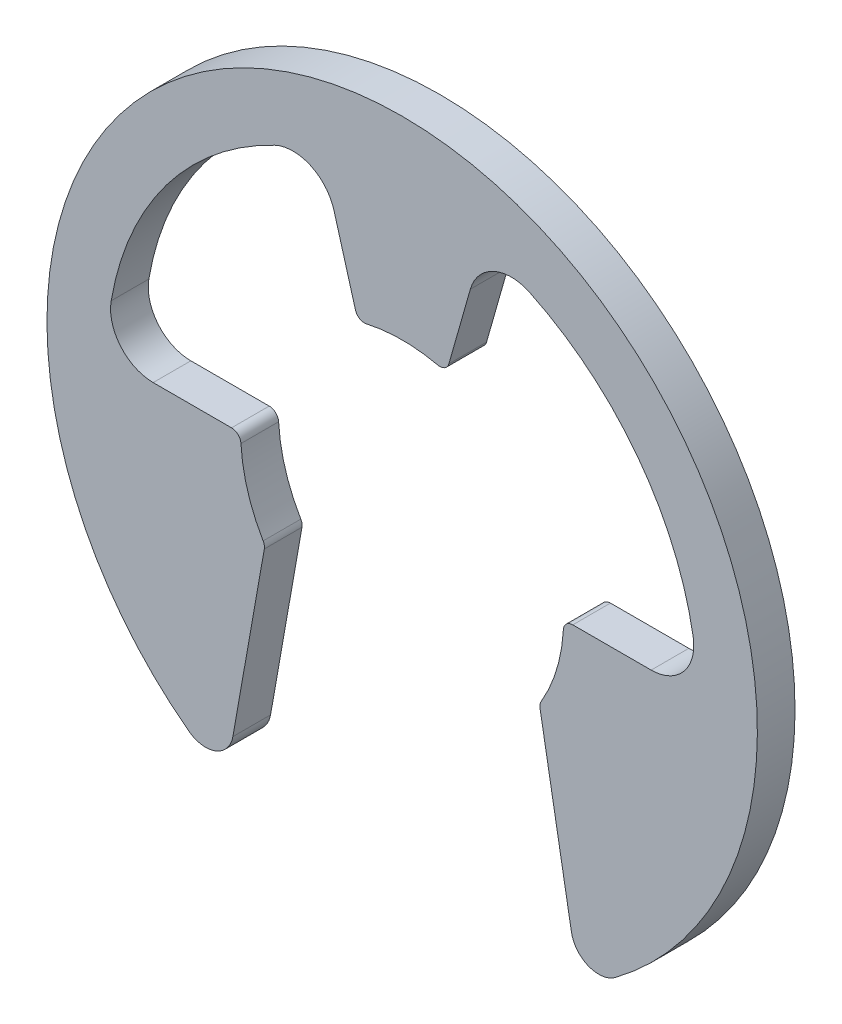
from build123d import *

# Parameters (mm, degrees)
SKETCH3_W               = 8.382
SKETCH3_H               = 0.889
CUT_EXTRUDE1_DEPTH      = 1.4445
CUT_EXTRUDE1_DEPTH_BACK = 1.4445
FILLET1_R               = 1.00584
FILLET2_R               = 0.653796
FILLET3_R               = 0.22225


with BuildPart() as part:
    # Sketch3 → Revolve1 (revolve)
    with BuildSketch(Plane(origin=(0, 0, 0), x_dir=(1, 0, 0), z_dir=(0, 1, 0))):
        with Locations((-4.191, 0)):
            Rectangle(SKETCH3_W, SKETCH3_H)
    revolve(axis=Axis((0, 0, -0.4445), (0, 0, 1)))

    # Sketch4 → Cut-Extrude1 (cut, two sides)
    with BuildSketch(Plane.XY) as cut_extrude1_sk:
        with BuildLine():
            Line((1.043411472, 3.664340664), (1.907952406, 6.700508642))
            ThreePointArc((1.907952406, 6.700508642), (5.560104779, 4.197896295), (6.966857143, 0))
            Line((6.966857143, 0), (3.81, 0))
            ThreePointArc((3.81, 0), (3.664340664, -1.043411472), (3.2385, -2.00704204))
            Line((3.2385, -2.00704204), (4.167000213, -7.27282842))
            ThreePointArc((4.167000213, -7.27282842), (0, -8.382), (-4.167000213, -7.27282842))
            Line((-4.167000213, -7.27282842), (-3.2385, -2.00704204))
            ThreePointArc((-3.2385, -2.00704204), (-3.664340664, -1.043411472), (-3.81, 0))
            Line((-3.81, 0), (-6.966857143, 0))
            ThreePointArc((-6.966857143, 0), (-5.560104779, 4.197896295), (-1.907952406, 6.700508642))
            Line((-1.907952406, 6.700508642), (-1.043411472, 3.664340664))
            ThreePointArc((-1.043411472, 3.664340664), (0, 3.81), (1.043411472, 3.664340664))
        make_face()
    extrude(amount=CUT_EXTRUDE1_DEPTH, mode=Mode.SUBTRACT)
    extrude(cut_extrude1_sk.sketch, amount=-CUT_EXTRUDE1_DEPTH_BACK, mode=Mode.SUBTRACT)

    # Fillet1
    fillet1_edges = [part.edges().sort_by_distance(p)[0] for p in [
        (1.907952406, 6.700508642, 0),
        (6.966857143, 0, 0),
        (-6.966857143, 0, 0),
        (-1.907952406, 6.700508642, 0),
    ]]
    fillet(fillet1_edges, radius=FILLET1_R)

    # Fillet2
    fillet2_edges = [part.edges().sort_by_distance(p)[0] for p in [
        (4.167000213, -7.27282842, 0),
        (-4.167000213, -7.27282842, 0),
    ]]
    fillet(fillet2_edges, radius=FILLET2_R)

    # Fillet3
    fillet3_edges = [part.edges().sort_by_distance(p)[0] for p in [
        (-1.043411472, 3.664340664, 0),
        (1.043411472, 3.664340664, 0),
        (3.81, 0, 0),
        (3.2385, -2.00704204, 0),
        (-3.2385, -2.00704204, 0),
        (-3.81, 0, 0),
    ]]
    fillet(fillet3_edges, radius=FILLET3_R)


solid = part.part
